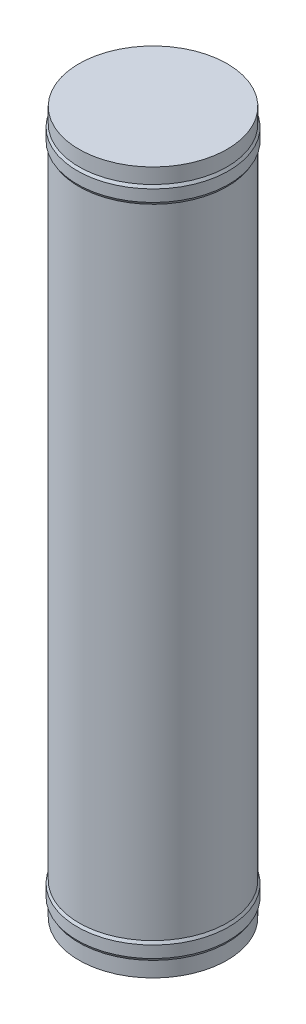
from build123d import *


with BuildPart() as part:
    # Sketch1 → Revolve2 (revolve)
    with BuildSketch(Plane.XY):
        Polygon((0, -45), (0, 45), (9.5, 45), (9.5, 43.05), (9.7, 42.703589838), (9.7, 41.203589838), (9.5, 40.857179677), (9.5, -40.857179677), (9.7, -41.203589838), (9.7, -42.703589838), (9.5, -43.05), (9.5, -45), align=None)
    revolve(axis=Axis((0, -45, 0), (0, 1, 0)))


solid = part.part
